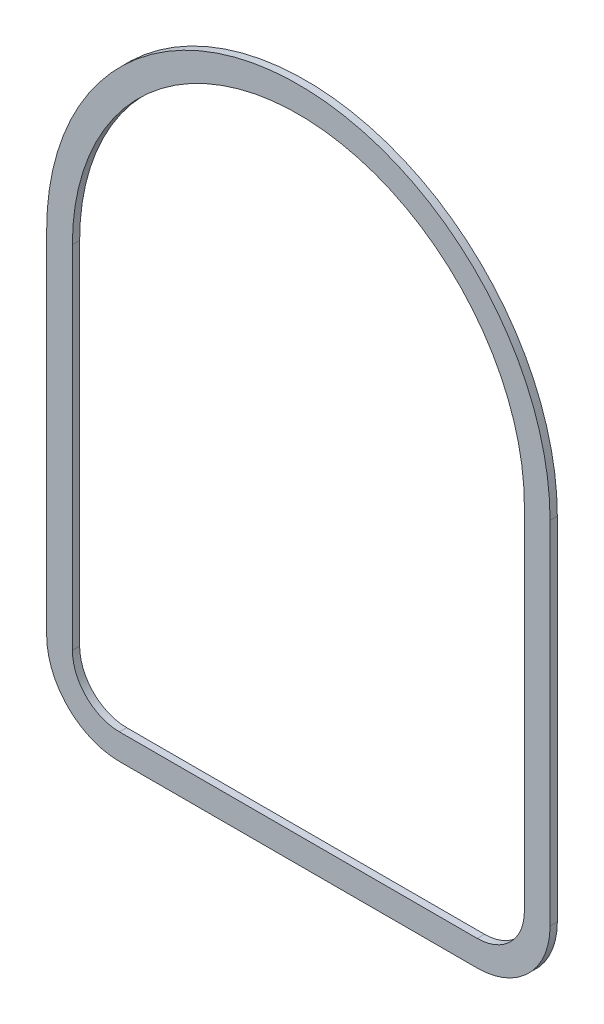
from build123d import *

# Parameters (mm, degrees)
BOSS_EXTRUDE1_DEPTH = 10


with BuildPart() as part:
    # Sketch2 → Boss-Extrude1 (new body)
    with BuildSketch(Plane.XY):
        with BuildLine():
            Line((340.245573827, -360.346945872), (340.245573827, 123.523054128))
            ThreePointArc((340.245573827, 123.523054128), (-6.464426173, 470.233054128), (-353.174426173, 123.523054128))
            Line((-353.174426173, 123.523054128), (-353.174426173, -360.346945872))
            ThreePointArc((-353.174426173, -360.346945872), (-323.78844953, -431.290969228), (-252.844426173, -460.676945872))
            Line((-252.844426173, -460.676945872), (239.915573827, -460.676945872))
            ThreePointArc((239.915573827, -460.676945872), (310.859597183, -431.290969228), (340.245573827, -360.346945872))
        make_face()
        with BuildLine():
            ThreePointArc((304.845573827, 123.523054128), (-6.464426173, 434.833054128), (-317.774426173, 123.523054128))
            Line((-317.774426173, 123.523054128), (-317.774426173, -360.346945872))
            ThreePointArc((-317.774426173, -360.346945872), (-298.756869476, -406.259389174), (-252.844426173, -425.276945872))
            Line((-252.844426173, -425.276945872), (239.915573827, -425.276945872))
            ThreePointArc((239.915573827, -425.276945872), (285.828017129, -406.259389174), (304.845573827, -360.346945872))
            Line((304.845573827, -360.346945872), (304.845573827, 123.523054128))
        make_face(mode=Mode.SUBTRACT)
    extrude(amount=BOSS_EXTRUDE1_DEPTH)


solid = part.part
